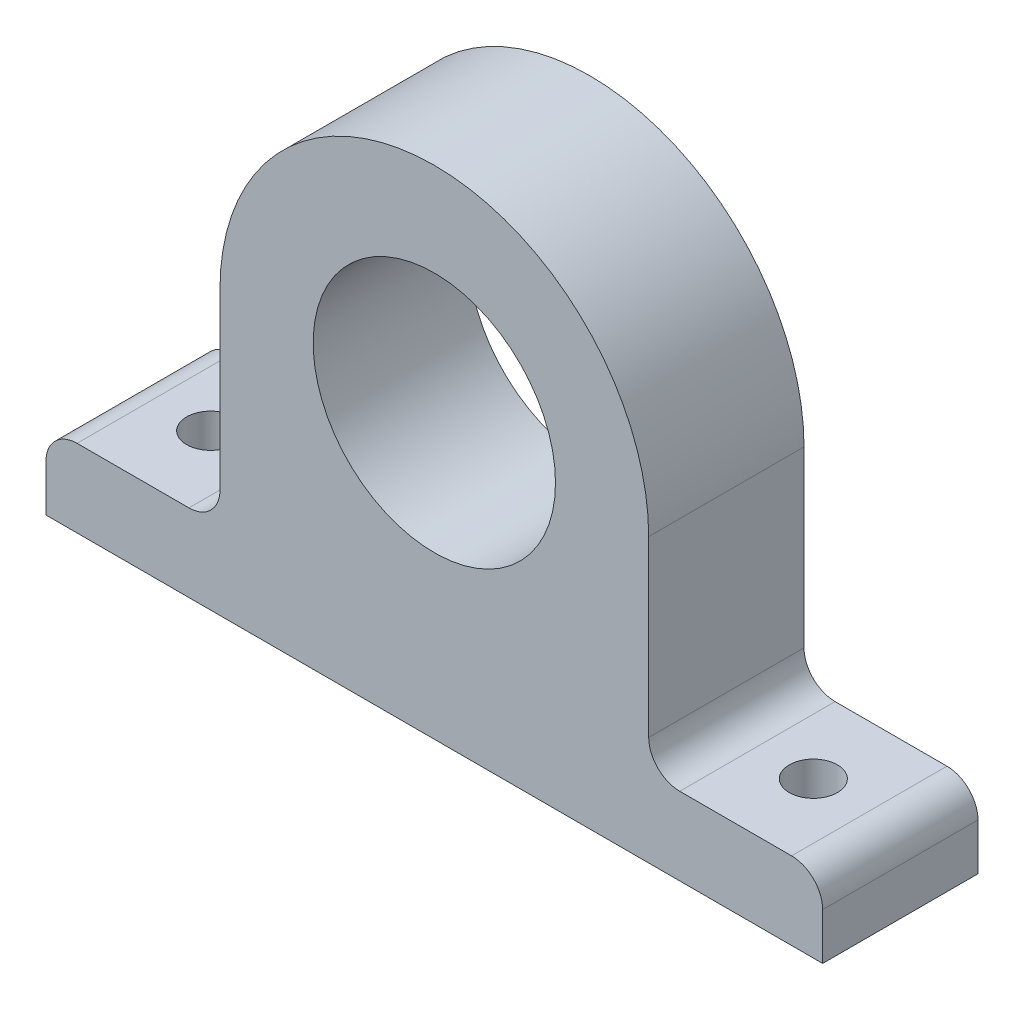
from build123d import *

# Parameters (mm, degrees)
SKETCH1_R           = 7.8
BOSS_EXTRUDE1_DEPTH = 10
SKETCH2_R           = 1.55
CUT_EXTRUDE1_DEPTH  = 5
FILLET1_R           = 2


with BuildPart() as part:
    # Sketch1 → Boss-Extrude1 (new body)
    with BuildSketch(Plane.XY):
        with BuildLine():
            Line((-25, 0), (25, 0))
            Line((25, 0), (25, 5))
            Line((25, 5), (13.8, 5))
            Line((13.8, 5), (13.8, 18.2))
            ThreePointArc((13.8, 18.2), (0, 32), (-13.8, 18.2))
            Line((-13.8, 18.2), (-13.8, 5))
            Line((-13.8, 5), (-25, 5))
            Line((-25, 5), (-25, 0))
        make_face()
        with Locations((0, 18.2)):
            Circle(SKETCH1_R, mode=Mode.SUBTRACT)
    extrude(amount=-BOSS_EXTRUDE1_DEPTH)

    # Sketch2 → Cut-Extrude1 (cut)
    with BuildSketch(Plane(origin=(0, 5, 0), x_dir=(1, 0, 0), z_dir=(0, 1, 0))):
        with Locations((-19.4, 5)):
            Circle(SKETCH2_R)
    cut_extrude1 = extrude(amount=-CUT_EXTRUDE1_DEPTH, mode=Mode.SUBTRACT)

    # Mirror1: Cut-Extrude1 across plane
    add(cut_extrude1.mirror(Plane(origin=(0, 0, 0), x_dir=(0, 0, 1), z_dir=(1, 0, 0))), mode=Mode.SUBTRACT)

    # Fillet1
    fillet1_edges = [part.edges().sort_by_distance(p)[0] for p in [
        (-25, 5, -5),
        (-13.8, 5, -5),
        (13.8, 5, -5),
        (25, 5, -5),
    ]]
    fillet(fillet1_edges, radius=FILLET1_R)


solid = part.part
